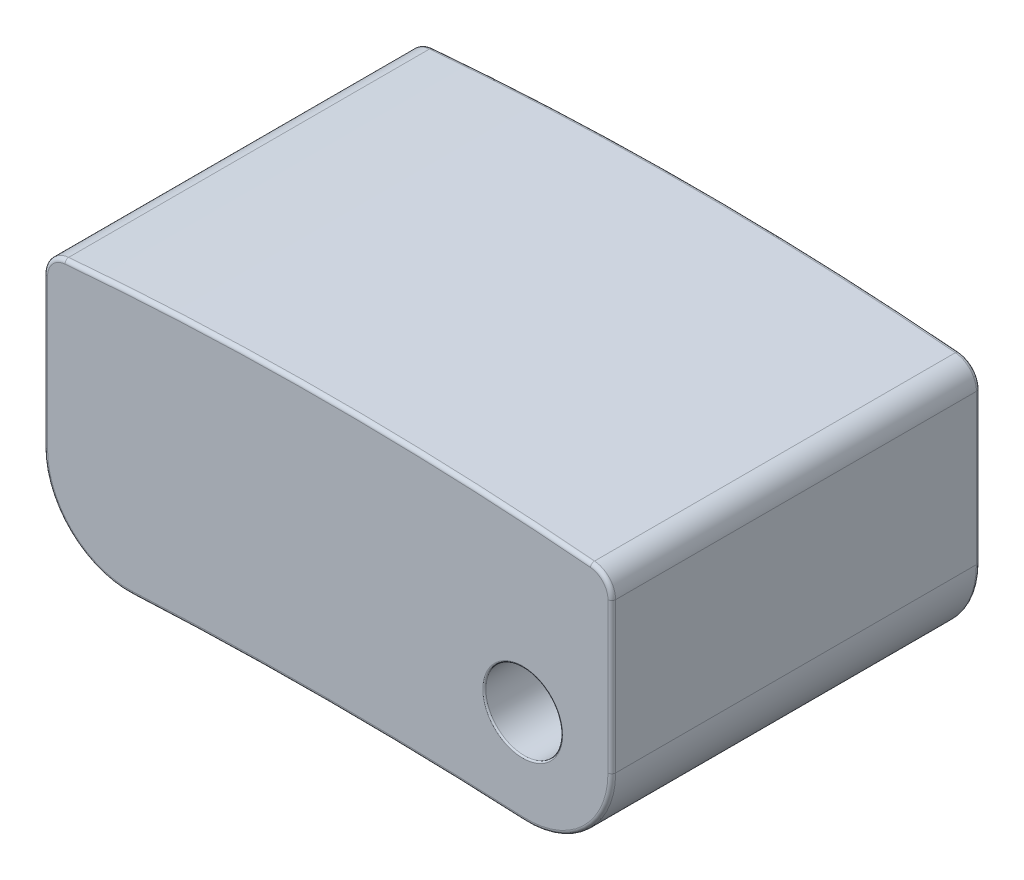
from build123d import *

# Parameters (mm, degrees)
SKETCH1_W               = 7.4
SKETCH1_H               = 3.7
BOSS_EXTRUDE1_DEPTH     = 2.4
CUT_EXTRUDE1_DEPTH      = 4.8
FILLET1_R               = 1.1
FILLET2_R               = 0.3
FILLET3_R               = 0.05
CUT_EXTRUDE2_START      = -1
SKETCH3_R               = 0.5
CUT_EXTRUDE2_DEPTH      = 7.4
FILLET4_R               = 0.02
CUT_EXTRUDE3_START      = 1
SKETCH4_R               = 0.5
CUT_EXTRUDE3_DEPTH      = 4.5
CUT_EXTRUDE4_REACH      = 16.756
CUT_EXTRUDE4_END_RADIUS = 50.4
CUT_EXTRUDE4_START      = -10
SKETCH5_R               = 0.4
FILLET5_R               = 0.05


with BuildPart() as part:
    # Sketch1 → Boss-Extrude1 (new, symmetric)
    with BuildSketch(Plane.XY):
        Rectangle(SKETCH1_W, SKETCH1_H)
    extrude(amount=BOSS_EXTRUDE1_DEPTH, both=True)

    # Sketch2 → Cut-Extrude1 (cut)
    with BuildSketch(Plane.XY.offset(2.4)):
        with BuildLine():
            Line((-3.7, 1.55), (-7.120690005, 4.011417256))
            Line((-7.120690005, 4.011417256), (5.535860742, 3.886722174))
            Line((5.535860742, 3.886722174), (3.7, 1.55))
            ThreePointArc((3.7, 1.55), (0, 1.721492621), (-3.7, 1.55))
        make_face()
        with BuildLine():
            Line((3.7, -1.85), (0.350623614, -3.782025322))
            Line((0.350623614, -3.782025322), (-3.7, -1.85))
            ThreePointArc((-3.7, -1.85), (0, -1.712912069), (3.7, -1.85))
        make_face()
    extrude(amount=-CUT_EXTRUDE1_DEPTH, mode=Mode.SUBTRACT)

    # Fillet1
    fillet1_edges = [part.edges().sort_by_distance(p)[0] for p in [
        (3.7, -1.85, 0),
        (-3.7, -1.85, 0),
    ]]
    fillet(fillet1_edges, radius=FILLET1_R)

    # Fillet2
    fillet2_edges = [part.edges().sort_by_distance(p)[0] for p in [
        (3.7, 1.55, 0),
        (-3.7, 1.55, 0),
    ]]
    fillet(fillet2_edges, radius=FILLET2_R)

    # Fillet3
    fillet3_edges = [part.edges().sort_by_distance(p)[0] for p in [
        (3.7, 0.298266493, -2.4),
        (3.7, 0.298266493, 2.4),
        (0, -1.712912069, -2.4),
        (-3.35777122, -1.476459629, -2.4),
        (3.35777122, -1.476459629, -2.4),
        (0, -1.712912069, 2.4),
        (-3.35777122, -1.476459629, 2.4),
        (3.35777122, -1.476459629, 2.4),
        (0, 1.721492621, 2.4),
        (-3.7, 0.298266493, 2.4),
        (-3.621029193, 1.478477738, 2.4),
        (3.621029193, 1.478477738, 2.4),
        (0, 1.721492621, -2.4),
        (-3.7, 0.298266493, -2.4),
        (-3.621029193, 1.478477738, -2.4),
        (3.621029193, 1.478477738, -2.4),
    ]]
    fillet(fillet3_edges, radius=FILLET3_R)

    # Sketch3 → Cut-Extrude2 (cut, symmetric)
    with BuildSketch(Plane.XY.offset(2.4).offset(CUT_EXTRUDE2_START)):
        with Locations((2.539436079, -0.548443568)):
            Circle(SKETCH3_R)
    extrude(amount=CUT_EXTRUDE2_DEPTH, both=True, mode=Mode.SUBTRACT)

    # Fillet4
    fillet4_edges = [part.edges().sort_by_distance(p)[0] for p in [
        (2.039436079, -0.548443568, 2.4),
        (2.039436079, -0.548443568, -2.4),
    ]]
    fillet(fillet4_edges, radius=FILLET4_R)

    # Sketch4 → Cut-Extrude3 (cut)
    with BuildSketch(Plane(origin=(0, 0, -2.4), x_dir=(-1, 0, 0), z_dir=(0, 0, -1)).offset(CUT_EXTRUDE3_START)):
        with Locations((2, -0.5)):
            Circle(SKETCH4_R)
    extrude(amount=-CUT_EXTRUDE3_DEPTH, mode=Mode.SUBTRACT)

    # Cut-Extrude4: up to this cylinder (the profile starts inside it)
    cut_extrude4_end = Plane(origin=(0, -51.712912069, -1), z_dir=(0, 0, 1)) * Cylinder(CUT_EXTRUDE4_END_RADIUS, 135.312, mode=Mode.PRIVATE)
    # Sketch5 → Cut-Extrude4 (cut, up to the surface)
    with BuildSketch(Plane(origin=(0, 0, 0), x_dir=(1, 0, 0), z_dir=(0, 1, 0)).offset(CUT_EXTRUDE4_START), mode=Mode.PRIVATE) as cut_extrude4_sk1:
        with Locations(Location((0.7, 1, 0), (0, 0, 90))):
            Circle(SKETCH5_R)
    cut_extrude4_tool1 = extrude(cut_extrude4_sk1.sketch, amount=CUT_EXTRUDE4_REACH, mode=Mode.PRIVATE) & cut_extrude4_end
    add(cut_extrude4_tool1.solids().sort_by_distance((0.7, -10, -1))[0], mode=Mode.SUBTRACT)

    # Fillet5
    fillet5_edges = [part.edges().sort_by_distance(p)[0] for p in [
        (0.700029875, -1.717812727, -0.600000001),
    ]]
    fillet(fillet5_edges, radius=FILLET5_R)


solid = part.part
